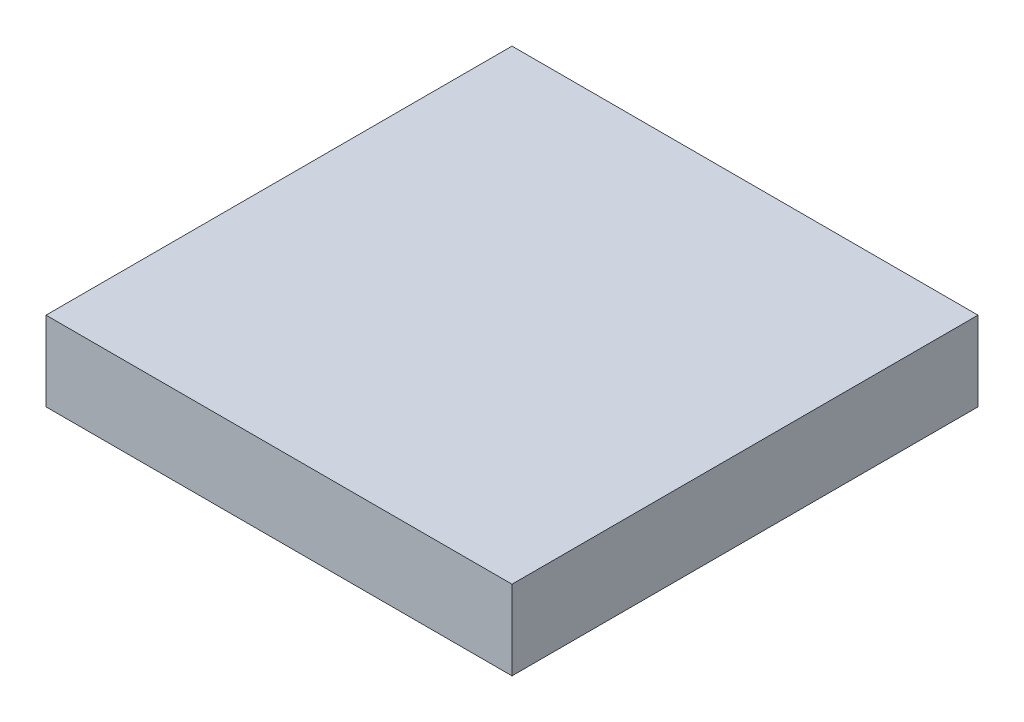
from build123d import *

# Parameters (mm, degrees)
SKETCH1_W           = 22
SKETCH1_H           = 22
BOSS_EXTRUDE1_DEPTH = 3.75


with BuildPart() as part:
    # Sketch1 → Boss-Extrude1 (new body)
    with BuildSketch(Plane(origin=(0, 0, 0), x_dir=(1, 0, 0), z_dir=(0, 1, 0))):
        Rectangle(SKETCH1_W, SKETCH1_H)
    extrude(amount=BOSS_EXTRUDE1_DEPTH)


solid = part.part
